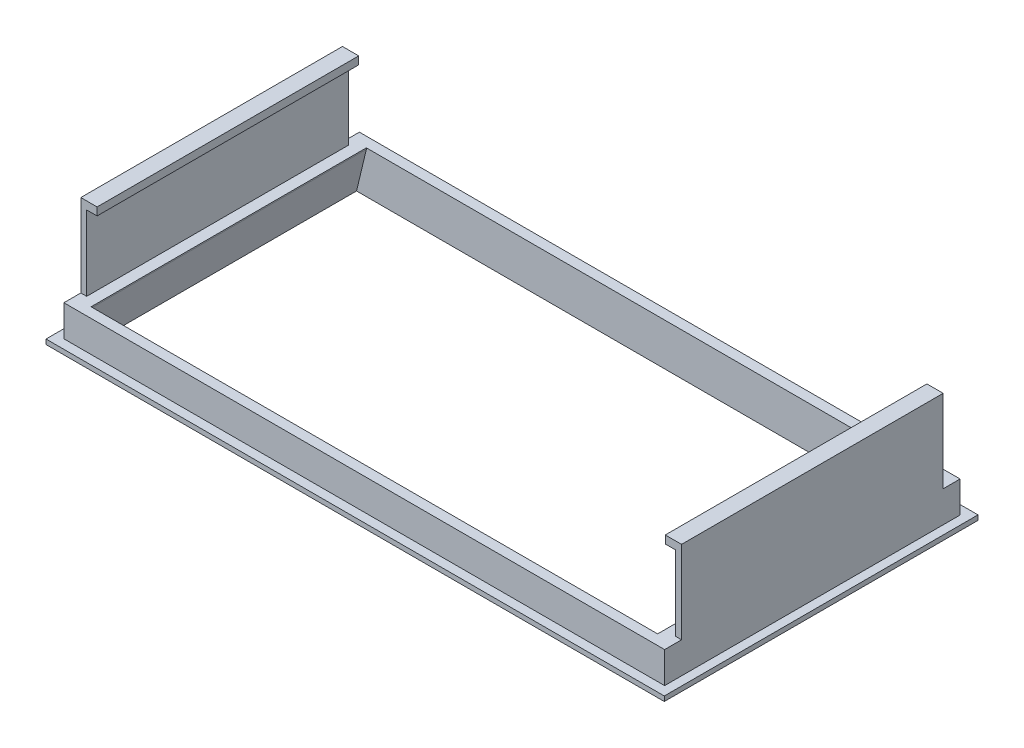
from build123d import *

# Parameters (mm, degrees)
SKETCH1_W            = 95
SKETCH1_H            = 48.2
BOSS_EXTRUDE2_DEPTH  = 1.7
SKETCH3_W            = 92.3
SKETCH3_H            = 45.4
BOSS_EXTRUDE3_DEPTH  = 4.8
SKETCH4_W            = 87.05
SKETCH4_H            = 42.3
CUT_EXTRUDE1_DEPTH   = 7.5
CHAMFER1_SIZE        = 0.96
CHAMFER2_SIZE        = 0.96
CHAMFER3_SIZE        = 0.96
CHAMFER4_SIZE        = 0.96
CHAMFER5_SIZE        = 6.31
CHAMFER5_SIZE2       = 1.51
CHAMFER6_SIZE        = 6.31
CHAMFER6_SIZE2       = 1.51
SKETCH5_W            = 92.3
SKETCH5_H            = 40.2
BOSS_EXTRUDE11_DEPTH = 11.5
SKETCH6_W            = 90.5
SKETCH6_H            = 40.2
CUT_EXTRUDE2_DEPTH   = 11.5
SKETCH7_W            = 92.3
SKETCH7_H            = 40.2
BOSS_EXTRUDE12_DEPTH = 1.2
SKETCH8_W            = 87.3
SKETCH8_H            = 40.2
CUT_EXTRUDE3_DEPTH   = 1.2


with BuildPart() as part:
    # Sketch1 → Boss-Extrude2 (new body)
    with BuildSketch(Plane(origin=(0, 0, 0), x_dir=(1, 0, 0), z_dir=(0, 1, 0))):
        Rectangle(SKETCH1_W, SKETCH1_H)
    extrude(amount=BOSS_EXTRUDE2_DEPTH)

    # Sketch3 → Boss-Extrude3 (add)
    with BuildSketch(Plane(origin=(0, 1.7, 0), x_dir=(1, 0, 0), z_dir=(0, 1, 0))):
        Rectangle(SKETCH3_W, SKETCH3_H)
    extrude(amount=BOSS_EXTRUDE3_DEPTH)

    # Sketch4 → Cut-Extrude1 (cut, through all)
    with BuildSketch(Plane(origin=(0, 6.5, 0), x_dir=(-1, 0, 0), z_dir=(0, 1, 0))):
        Rectangle(SKETCH4_W, SKETCH4_H)
    extrude(amount=-CUT_EXTRUDE1_DEPTH, mode=Mode.SUBTRACT)

    # Chamfer1
    chamfer1_edges = [part.edges().sort_by_distance(p)[0] for p in [
        (47.5, 0, 0),
    ]]
    chamfer(chamfer1_edges, length=CHAMFER1_SIZE)

    # Chamfer2
    chamfer2_edges = [part.edges().sort_by_distance(p)[0] for p in [
        (-0.48, 0, -24.1),
    ]]
    chamfer(chamfer2_edges, length=CHAMFER2_SIZE)

    # Chamfer3
    chamfer3_edges = [part.edges().sort_by_distance(p)[0] for p in [
        (-47.5, 0, 0.48),
    ]]
    chamfer(chamfer3_edges, length=CHAMFER3_SIZE)

    # Chamfer4
    chamfer4_edges = [part.edges().sort_by_distance(p)[0] for p in [
        (0, 0, 24.1),
    ]]
    chamfer(chamfer4_edges, length=CHAMFER4_SIZE)

    # Chamfer5
    chamfer5_edges = [part.edges().sort_by_distance(p)[0] for p in [
        (-43.525, 0, 0),
    ]]
    chamfer5_side = [part.faces().sort_by_distance(p)[0] for p in [
        (-43.525, 3.25, 0),
    ]]
    chamfer(chamfer5_edges, length=CHAMFER5_SIZE, length2=CHAMFER5_SIZE2, reference=chamfer5_side[0])

    # Chamfer6
    chamfer6_edges = [part.edges().sort_by_distance(p)[0] for p in [
        (43.525, 0, 0),
    ]]
    chamfer6_side = [part.faces().sort_by_distance(p)[0] for p in [
        (43.525, 3.25, 0),
    ]]
    chamfer(chamfer6_edges, length=CHAMFER6_SIZE, length2=CHAMFER6_SIZE2, reference=chamfer6_side[0])

    # Sketch5 → Boss-Extrude11 (add)
    with BuildSketch(Plane(origin=(0, 6.5, 0), x_dir=(1, 0, 0), z_dir=(0, 1, 0))):
        Rectangle(SKETCH5_W, SKETCH5_H)
    extrude(amount=BOSS_EXTRUDE11_DEPTH)

    # Sketch6 → Cut-Extrude2 (cut)
    with BuildSketch(Plane(origin=(0, 18, 0), x_dir=(1, 0, 0), z_dir=(0, 1, 0))):
        Rectangle(SKETCH6_W, SKETCH6_H)
    extrude(amount=-CUT_EXTRUDE2_DEPTH, mode=Mode.SUBTRACT)

    # Sketch7 → Boss-Extrude12 (add)
    with BuildSketch(Plane(origin=(0, 18, 0), x_dir=(-1, 0, 0), z_dir=(0, 1, 0))):
        Rectangle(SKETCH7_W, SKETCH7_H)
    extrude(amount=BOSS_EXTRUDE12_DEPTH)

    # Sketch8 → Cut-Extrude3 (cut)
    with BuildSketch(Plane(origin=(0, 19.2, 0), x_dir=(1, 0, 0), z_dir=(0, 1, 0))):
        Rectangle(SKETCH8_W, SKETCH8_H)
    extrude(amount=-CUT_EXTRUDE3_DEPTH, mode=Mode.SUBTRACT)


solid = part.part
